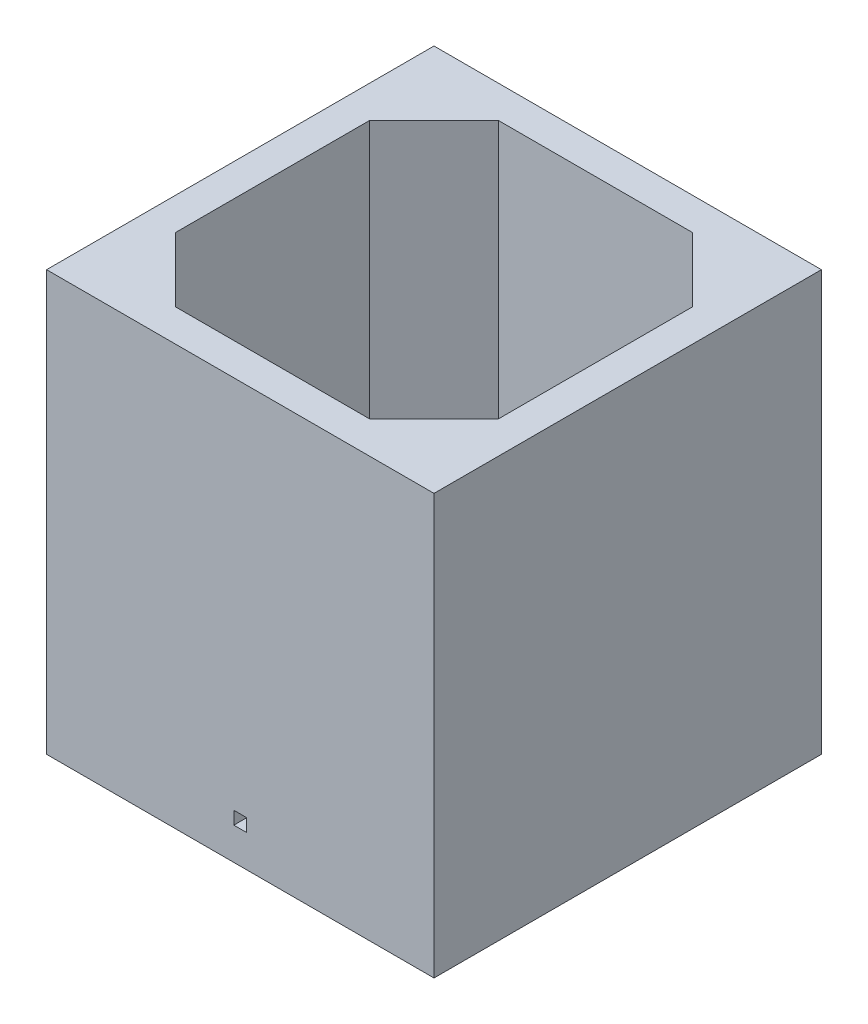
from build123d import *

# Parameters (mm, degrees)
SKETCH1_W           = 60
SKETCH1_H           = 60
SKETCH1_W_2         = 50
SKETCH1_H_2         = 50
BOSS_EXTRUDE1_DEPTH = 60
SKETCH2_W           = 60
SKETCH2_H           = 60
BOSS_EXTRUDE2_DEPTH = 5
SKETCH3_R           = 1.25
CUT_EXTRUDE1_DEPTH  = 5
CUT_EXTRUDE2_REACH  = 62
SKETCH4_R           = 1.25
CHAMFER1_SIZE       = 10
CUT_EXTRUDE4_REACH  = 62
SKETCH6_W           = 2
SKETCH6_H           = 2


with BuildPart() as part:
    # Sketch1 → Boss-Extrude1 (new body)
    with BuildSketch(Plane(origin=(0, 0, 0), x_dir=(1, 0, 0), z_dir=(0, 1, 0))):
        Rectangle(SKETCH1_W, SKETCH1_H)
        Rectangle(SKETCH1_W_2, SKETCH1_H_2, mode=Mode.SUBTRACT)
    extrude(amount=BOSS_EXTRUDE1_DEPTH)

    # Sketch2 → Boss-Extrude2 (add)
    with BuildSketch(Plane.XZ):
        Rectangle(SKETCH2_W, SKETCH2_H)
    extrude(amount=BOSS_EXTRUDE2_DEPTH)

    # Sketch3 → Cut-Extrude1 (cut)
    with BuildSketch(Plane(origin=(0, 0, -30), x_dir=(-1, 0, 0), z_dir=(0, 0, -1))):
        with Locations((0, 2.5)):
            Circle(SKETCH3_R)
        with Locations((0, 8.1)):
            Circle(SKETCH3_R)
    extrude(amount=-CUT_EXTRUDE1_DEPTH, mode=Mode.SUBTRACT)

    # Sketch4 → Cut-Extrude2 (cut, up to next)
    with BuildSketch(Plane(origin=(0, 0, -30), x_dir=(-1, 0, 0), z_dir=(0, 0, -1)), mode=Mode.PRIVATE) as cut_extrude2_sk1:
        with Locations((-13.176528006, 8.1)):
            Circle(SKETCH4_R)
    cut_extrude2_tool1 = extrude(cut_extrude2_sk1.sketch, amount=-CUT_EXTRUDE2_REACH, mode=Mode.PRIVATE) & part.part
    add(cut_extrude2_tool1.solids().sort_by_distance((13.176528, 8.1, -30))[0], mode=Mode.SUBTRACT)

    # Chamfer1
    chamfer1_edges = [part.edges().sort_by_distance(p)[0] for p in [
        (25, 30, 25),
        (25, 30, -25),
        (-25, 30, -25),
        (-25, 30, 25),
    ]]
    chamfer(chamfer1_edges, length=CHAMFER1_SIZE)

    # Sketch6 → Cut-Extrude4 (cut, up to next)
    with BuildSketch(Plane.XY.offset(30), mode=Mode.PRIVATE) as cut_extrude4_sk1:
        with Locations((0, 1)):
            Rectangle(SKETCH6_W, SKETCH6_H)
    cut_extrude4_tool1 = extrude(cut_extrude4_sk1.sketch, amount=-CUT_EXTRUDE4_REACH, mode=Mode.PRIVATE) & part.part
    add(cut_extrude4_tool1.solids().sort_by_distance((0, 1, 30))[0], mode=Mode.SUBTRACT)


solid = part.part
